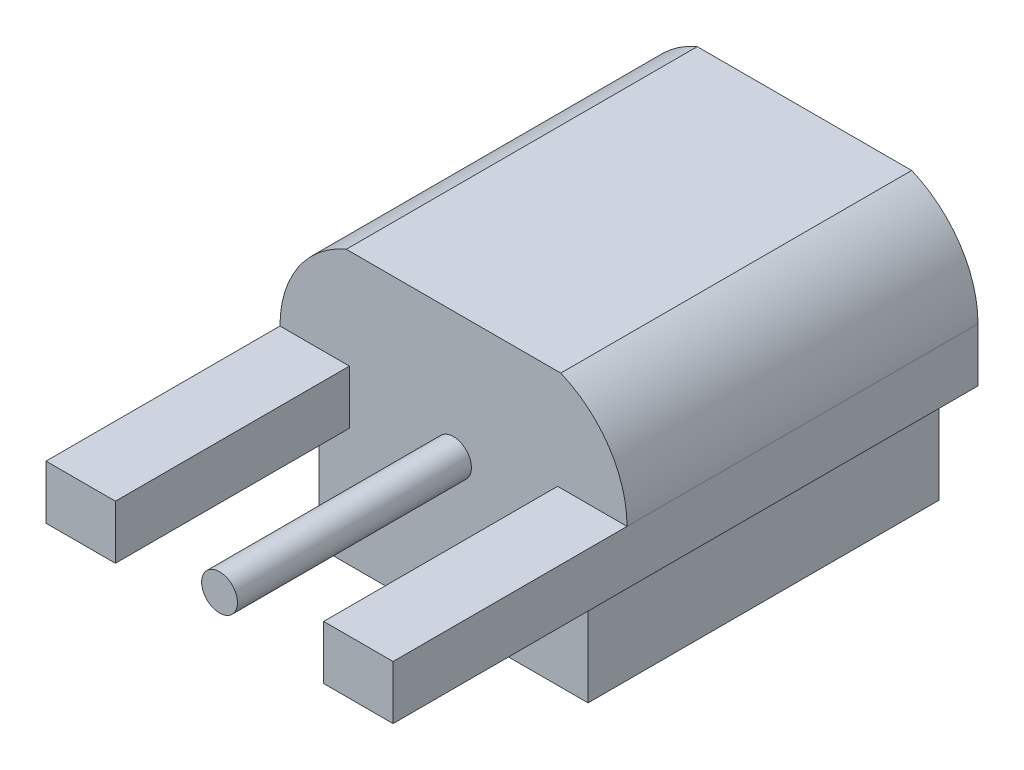
from build123d import *

# Parameters (mm, degrees)
BOSS_EXTRUDE2_DEPTH = 0.69
SKETCH3_W           = 3.45
SKETCH3_H           = 4.5
BOSS_EXTRUDE3_DEPTH = 1.52
SKETCH4_R           = 0.229716396
BOSS_EXTRUDE4_DEPTH = 3
BOSS_EXTRUDE5_DEPTH = 4.5
SKETCH6_R           = 1.19
CUT_EXTRUDE1_DEPTH  = 3


with BuildPart() as part:
    # Sketch1 → Boss-Extrude2 (new body)
    with BuildSketch(Plane(origin=(0, 0, 0), x_dir=(1, 0, 0), z_dir=(0, 1, 0))):
        Polygon((0.89, 3), (0.89, 0), (0, 0), (0, 7.5), (4.45, 7.5), (4.45, 0), (3.56, 0), (3.56, 3), align=None)
    extrude(amount=BOSS_EXTRUDE2_DEPTH)

    # Sketch3 → Boss-Extrude3 (add)
    with BuildSketch(Plane.XZ):
        with Locations((2.225, -5.25)):
            Rectangle(SKETCH3_W, SKETCH3_H)
    extrude(amount=BOSS_EXTRUDE3_DEPTH)

    # Sketch5 → Boss-Extrude5 (add)
    with BuildSketch(Plane(origin=(0, 0, -7.5), x_dir=(-1, 0, 0), z_dir=(0, 0, -1))):
        with BuildLine():
            Line((-3.6, 1.967420132), (-0.85, 1.967420132))
            ThreePointArc((-0.85, 1.967420132), (-0.231919135, 1.457186776), (0, 0.69))
            Line((0, 0.69), (-4.45, 0.69))
            ThreePointArc((-4.45, 0.69), (-4.218080865, 1.457186776), (-3.6, 1.967420132))
        make_face()
    extrude(amount=-BOSS_EXTRUDE5_DEPTH)

    # Sketch6 → Cut-Extrude1 (cut)
    with BuildSketch(Plane(origin=(0, 0, -7.5), x_dir=(-1, 0, 0), z_dir=(0, 0, -1))):
        with Locations((-2.225, 0.345)):
            Circle(SKETCH6_R)
    extrude(amount=-CUT_EXTRUDE1_DEPTH, mode=Mode.SUBTRACT)


with BuildPart() as body_2:
    # Sketch4 → Boss-Extrude4 (new body)
    with BuildSketch(Plane.XY.offset(-3)):
        with Locations((2.225, 0.345)):
            Circle(SKETCH4_R)
    extrude(amount=BOSS_EXTRUDE4_DEPTH)


solid = Compound([part.part, body_2.part])
